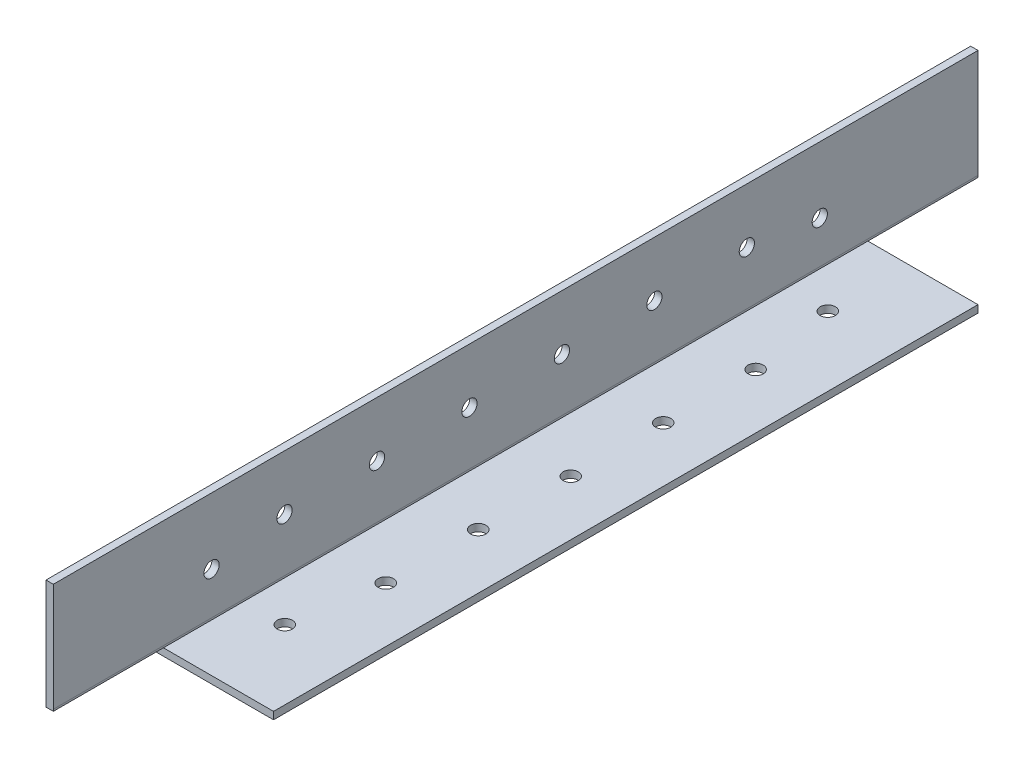
from build123d import *

# Parameters (mm, degrees)
BOSS_EXTRUDE1_DEPTH = 1219.2
FILLET1_R           = 0.254
SKETCH4_W           = 2238.4
SKETCH4_H           = 74.945320812
CUT_EXTRUDE1_DEPTH  = 60
SKETCH8_W           = 23.813
SKETCH8_H           = 23.813
CUT_EXTRUDE6_DEPTH  = 28.313
CUT_EXTRUDE7_DEPTH  = 228.313
SKETCH10_W          = 23.813
SKETCH10_H          = 1.587
CUT_EXTRUDE8_DEPTH  = 228.313
SKETCH14_R          = 1.65
CUT_EXTRUDE11_DEPTH = 60
SKETCH15_R          = 1.65
CUT_EXTRUDE12_DEPTH = 60


with BuildPart() as part:
    # Sketch3 → Boss-Extrude1 (new, symmetric)
    with BuildSketch(Plane.XY):
        Polygon((1.5875, 25.4), (0, 25.4), (0, 0), (25.4, 0), (25.4, 1.5875), (1.5875, 1.5875), align=None)
    extrude(amount=BOSS_EXTRUDE1_DEPTH, both=True)

    # Fillet1
    fillet1_edges = [part.edges().sort_by_distance(p)[0] for p in [
        (1.5875, 1.5875, 0),
    ]]
    fillet(fillet1_edges, radius=FILLET1_R)

    # Sketch4 → Cut-Extrude1 (cut)
    with BuildSketch(Plane.ZY):
        with Locations((-100, 37.472660406)):
            Rectangle(SKETCH4_W, SKETCH4_H)
    extrude(amount=-CUT_EXTRUDE1_DEPTH, mode=Mode.SUBTRACT)

    # Sketch8 → Cut-Extrude6 (cut)
    with BuildSketch(Plane(origin=(0, 1.5875, 0), x_dir=(1, 0, 0), z_dir=(0, 1, 0))):
        with Locations((13.4935, -1207.2935)):
            Rectangle(SKETCH8_W, SKETCH8_H)
        with Locations((13.4935, -1031.1065)):
            Rectangle(SKETCH8_W, SKETCH8_H)
    extrude(amount=-CUT_EXTRUDE6_DEPTH, mode=Mode.SUBTRACT)

    # Sketch9 → Cut-Extrude7 (cut)
    with BuildSketch(Plane(origin=(0, 0, 1019.2), x_dir=(-1, 0, 0), z_dir=(0, 0, -1))):
        Polygon((-1.8415, 1.5875), (-1.587, 1.5875), (-1.5875, 1.990327362), (-1.8415, 1.990327362), align=None)
    extrude(amount=-CUT_EXTRUDE7_DEPTH, mode=Mode.SUBTRACT)

    # Sketch10 → Cut-Extrude8 (cut)
    with BuildSketch(Plane.ZY):
        with Locations((1207.2935, 0.7935)):
            Rectangle(SKETCH10_W, SKETCH10_H)
        with Locations((1031.1065, 0.7935)):
            Rectangle(SKETCH10_W, SKETCH10_H)
    extrude(amount=-CUT_EXTRUDE8_DEPTH, mode=Mode.SUBTRACT)

    # Sketch14 → Cut-Extrude11 (cut)
    with BuildSketch(Plane(origin=(0, 1.5875, 0), x_dir=(1, 0, 0), z_dir=(0, 1, 0))):
        with Locations(Location((10.3759, -1177.925, 0), (0, 0, 180))):
            Circle(SKETCH14_R)
        with Locations(Location((10.3759, -1060.4755, 0), (0, 0, 180))):
            Circle(SKETCH14_R)
        with Locations(Location((13.49375, -1079.20025, 0), (0, 0, 180))):
            Circle(SKETCH14_R)
        with Locations(Location((13.49375, -1099.20025, 0), (0, 0, 180))):
            Circle(SKETCH14_R)
        with Locations(Location((13.49375, -1119.20025, 0), (0, 0, 180))):
            Circle(SKETCH14_R)
        with Locations(Location((13.49375, -1139.20025, 0), (0, 0, 180))):
            Circle(SKETCH14_R)
        with Locations(Location((13.49375, -1159.20025, 0), (0, 0, 180))):
            Circle(SKETCH14_R)
    extrude(amount=-CUT_EXTRUDE11_DEPTH, mode=Mode.SUBTRACT)

    # Sketch15 → Cut-Extrude12 (cut)
    with BuildSketch(Plane(origin=(1.5875, 0, 0), x_dir=(0, 0, -1), z_dir=(1, 0, 0))):
        with Locations((-1184.978795667, 11.1125)):
            Circle(SKETCH15_R)
        with Locations((-1053.421204333, 11.1125)):
            Circle(SKETCH15_R)
        with Locations((-1069.2, 13.49375)):
            Circle(SKETCH15_R)
        with Locations((-1089.2, 13.49375)):
            Circle(SKETCH15_R)
        with Locations((-1109.2, 13.49375)):
            Circle(SKETCH15_R)
        with Locations((-1129.2, 13.49375)):
            Circle(SKETCH15_R)
        with Locations((-1149.2, 13.49375)):
            Circle(SKETCH15_R)
        with Locations((-1169.2, 13.49375)):
            Circle(SKETCH15_R)
    extrude(amount=-CUT_EXTRUDE12_DEPTH, mode=Mode.SUBTRACT)


solid = part.part
